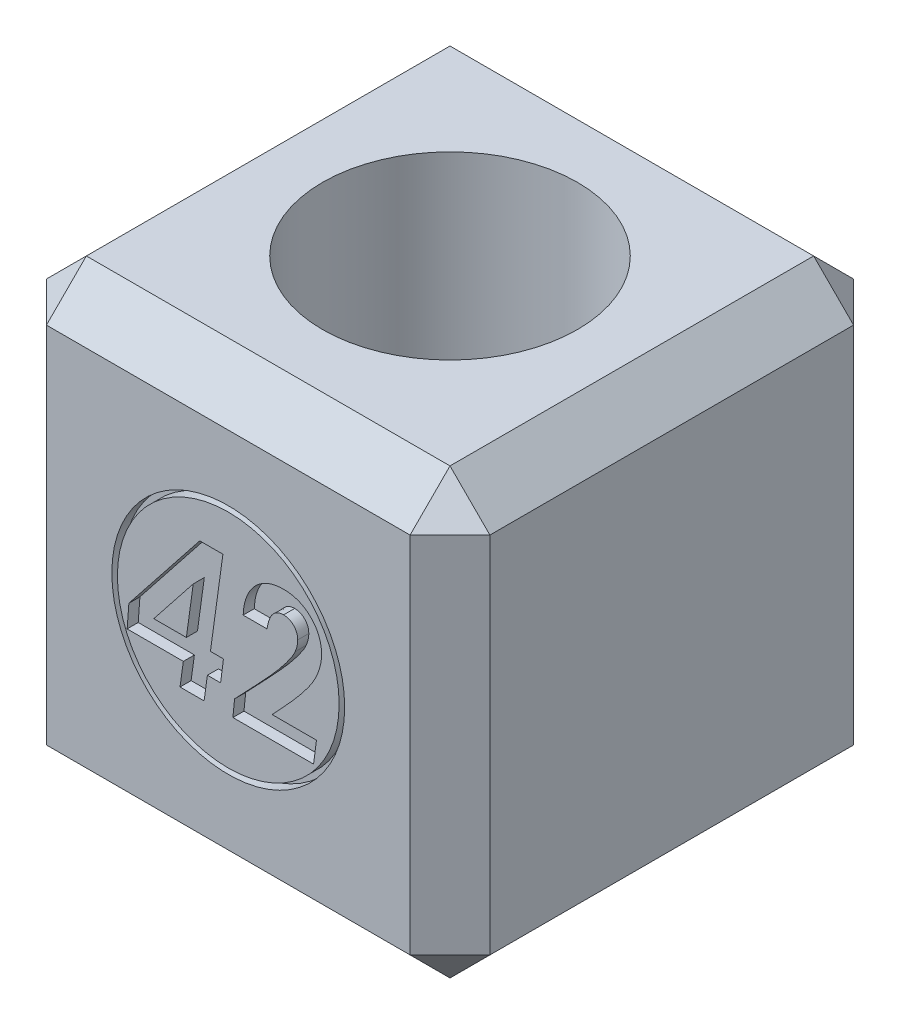
from build123d import *

# Parameters (mm, degrees)
SKETCH_1_W          = 200
SKETCH_1_H          = 200
EXTRUDE_1_DEPTH     = 200
CHAMFER_1_SIZE      = 18
SKETCH_2_R          = 57.5
CUT_EXTRUDE_1_DEPTH = 150
SKETCH_3_R          = 52.5
SKETCH_3_R_2        = 50
CUT_EXTRUDE_4_DEPTH = 5


with BuildPart() as part:
    # Sketch 1 → Extrude 1 (new body)
    with BuildSketch(Plane(origin=(0, 0, 0), x_dir=(0, 0, -1), z_dir=(1, 0, 0))):
        with Locations((100, 100)):
            Rectangle(SKETCH_1_W, SKETCH_1_H)
    extrude(amount=EXTRUDE_1_DEPTH)

    # Chamfer 1
    chamfer_1_edges = [part.edges().sort_by_distance(p)[0] for p in [
        (200, 100, -200),
        (200, 200, -100),
        (200, 100, 0),
        (0, 200, -100),
        (0, 100, -200),
        (0, 0, -100),
        (0, 100, 0),
        (200, 0, -100),
        (100, 200, 0),
        (100, 200, -200),
        (100, 0, -200),
        (100, 0, 0),
    ]]
    chamfer(chamfer_1_edges, length=CHAMFER_1_SIZE)

    # Sketch 2 → Cut-Extrude 1 (cut)
    with BuildSketch(Plane(origin=(0, 200, 0), x_dir=(1, 0, 0), z_dir=(0, 1, 0))):
        with Locations(Location((100, 100, 0), (0, 0, 270))):
            Circle(SKETCH_2_R)
    extrude(amount=-CUT_EXTRUDE_1_DEPTH, mode=Mode.SUBTRACT)

    # Sketch 3 → Cut-Extrude 4 (cut)
    with BuildSketch(Plane.XY):
        with Locations((100, 100)):
            Circle(SKETCH_3_R)
        with Locations((100, 100)):
            Circle(SKETCH_3_R_2, mode=Mode.SUBTRACT)
        with BuildLine():
            add(Edge.make_bspline(
                [(124.952810184, 122.311754672), (124.061928668, 122.316141415), (122.723328375, 122.065314477), (121.15976707, 121.17726781), (120.31812048, 120.404799304), (119.711791362, 119.661639483), (119.299662129, 118.992437635), (118.890623993, 118.246055909), (118.558018296, 117.387310251), (118.225423141, 116.448647339), (117.836741696, 115.008969129), (117.587459376, 113.876131637), (117.476848645, 113.080985442)],
                knots=[0, 0, 0, 0, 0.204127863, 0.304431221, 0.408409421, 0.463887314, 0.523727039, 0.588196002, 0.658593566, 0.734357814, 0.816313439, 1, 1, 1, 1], degree=3))
            Line((117.476848645, 113.080985442), (106.707617876, 113.080985442))
            add(Edge.make_bspline(
                [(106.707617876, 113.080985442), (106.781895264, 114.937649447), (107.131475338, 117.664732571), (108.237782966, 121.070374863), (109.302543269, 123.370468484), (110.613437766, 125.442055382), (112.132515124, 127.267990733), (113.875631172, 128.806059043), (115.795871388, 130.092952145), (117.895783577, 131.088301864), (120.9374414, 132.05768373), (123.358242769, 132.306151558), (124.988867876, 132.311754672)],
                knots=[0, 0, 0, 0, 0.188116369, 0.27589316, 0.361277617, 0.44378986, 0.523169186, 0.600666658, 0.678099482, 0.756216315, 0.834899655, 1, 1, 1, 1], degree=3))
            add(Edge.make_bspline(
                [(124.988867876, 132.311754672), (126.175754308, 132.315676764), (127.93496111, 132.179510664), (130.186678669, 131.655134145), (131.7726869, 131.129273666), (133.268472003, 130.437845008), (134.687294958, 129.602483287), (136.026293603, 128.613446176), (137.265267034, 127.476325352), (138.390653811, 126.231694174), (139.384787852, 124.902245602), (140.228434325, 123.499377361), (140.906924261, 122.013604885), (141.434573231, 120.458552141), (141.959304994, 118.255123496), (142.09551179, 116.535641705), (142.092233261, 115.376658519)],
                knots=[0, 0, 0, 0, 0.132319326, 0.195567087, 0.25726574, 0.318197153, 0.378841636, 0.440456231, 0.50334526, 0.56593404, 0.627190101, 0.688062599, 0.747996218, 0.808849065, 0.870792773, 1, 1, 1, 1], degree=3))
            add(Edge.make_bspline(
                [(142.092233261, 115.376658519), (142.09732202, 114.393518355), (141.95430932, 112.905639606), (141.581070463, 110.915109319), (141.148217608, 109.37826343), (140.624528159, 107.801834253), (139.967531924, 106.199142481), (139.199146108, 104.565449003), (138.455218348, 103.183260504), (137.779650529, 102.028028639), (137.171822841, 101.090201616), (136.490804976, 100.08130842), (135.711268931, 99.01064295), (134.866860384, 97.854812526), (133.910144174, 96.645058775), (132.880240035, 95.363192003), (131.771215601, 94.008863585), (130.567357552, 92.595436285), (129.285008389, 91.105753441), (127.911135514, 89.550736384), (126.443361597, 87.93660771), (124.906447454, 86.233134327), (122.679244122, 83.836732523), (120.967131822, 82.003308094), (119.784540953, 80.773293134)],
                knots=[0, 0, 0, 0, 0.069981715, 0.106336674, 0.144238498, 0.183709243, 0.224708791, 0.267639701, 0.312364973, 0.33656381, 0.36302672, 0.392021296, 0.423331852, 0.457435971, 0.494060334, 0.533269791, 0.574668339, 0.618846706, 0.665626965, 0.714798059, 0.766769623, 0.82116182, 0.878361292, 1, 1, 1, 1], degree=3))
            Line((119.784540953, 80.773293134), (139.784540953, 80.773293134))
            Line((139.784540953, 80.773293134), (138.462425568, 70.773293134))
            Line((138.462425568, 70.773293134), (102.092233261, 70.773293134))
            Line((102.092233261, 70.773293134), (102.86146403, 78.465600826))
            add(Edge.make_bspline(
                [(102.86146403, 78.465600826), (104.073053727, 79.737856076), (105.861414534, 81.588001167), (108.15811719, 84.030126363), (109.77444844, 85.719605027), (111.292181295, 87.342421418), (112.742192845, 88.873377879), (114.109044196, 90.319346392), (115.381760254, 91.694514713), (116.578546994, 92.97827206), (117.673765861, 94.197556125), (118.717301158, 95.306997342), (119.650706014, 96.356133448), (120.503599196, 97.32161107), (121.495876039, 98.422484298), (122.172586535, 99.230130727), (122.609060184, 99.727620057)],
                knots=[0, 0, 0, 0, 0.181614482, 0.265988361, 0.346548719, 0.423311675, 0.495675135, 0.564525855, 0.628995855, 0.68936882, 0.745950656, 0.798411213, 0.846803604, 0.891102717, 0.931584129, 1, 1, 1, 1], degree=3))
            add(Edge.make_bspline(
                [(122.609060184, 99.727620057), (123.542457488, 100.855288981), (124.884611957, 102.474543208), (126.494767665, 104.618871476), (127.522861077, 106.015472175), (128.390657407, 107.310563545), (129.306154563, 108.764488546), (129.869005007, 109.828049592), (130.157137107, 110.508870057)],
                knots=[0, 0, 0, 0, 0.332831745, 0.477817127, 0.609520417, 0.726973213, 0.832099586, 1, 1, 1, 1], degree=3))
            add(Edge.make_bspline(
                [(130.157137107, 110.508870057), (130.511822539, 111.366072382), (131.120426847, 113.057426489), (131.319730922, 114.845166367), (131.323002492, 115.701177749)],
                knots=[0, 0, 0, 0, 0.520562004, 1, 1, 1, 1], degree=3))
            add(Edge.make_bspline(
                [(131.323002492, 115.701177749), (131.302782595, 116.579231828), (131.136297941, 117.914660904), (130.3064802, 119.455009614), (129.500708922, 120.45075585), (128.538845138, 121.277303266), (127.061812678, 122.101056155), (125.792809521, 122.304509149), (124.952810184, 122.311754672)],
                knots=[0, 0, 0, 0, 0.259693846, 0.38313667, 0.508398189, 0.633351073, 0.752658268, 1, 1, 1, 1], degree=3))
        make_face()
        Polygon((55.169156338, 91.951177749), (87.140310184, 132.311754672), (97.585021722, 132.311754672), (91.960021722, 91.542523903), (97.837425568, 91.542523903), (96.539348645, 81.542523903), (90.589829415, 81.542523903), (89.099444799, 70.773293134), (78.246079415, 70.773293134), (79.73646403, 81.542523903), (54.399925568, 81.542523903), align=None)
        Polygon((81.106656338, 91.542523903), (84.207617876, 114.018485442), (66.407137107, 91.542523903), align=None, mode=Mode.SUBTRACT)
    extrude(amount=-CUT_EXTRUDE_4_DEPTH, mode=Mode.SUBTRACT)


solid = part.part
